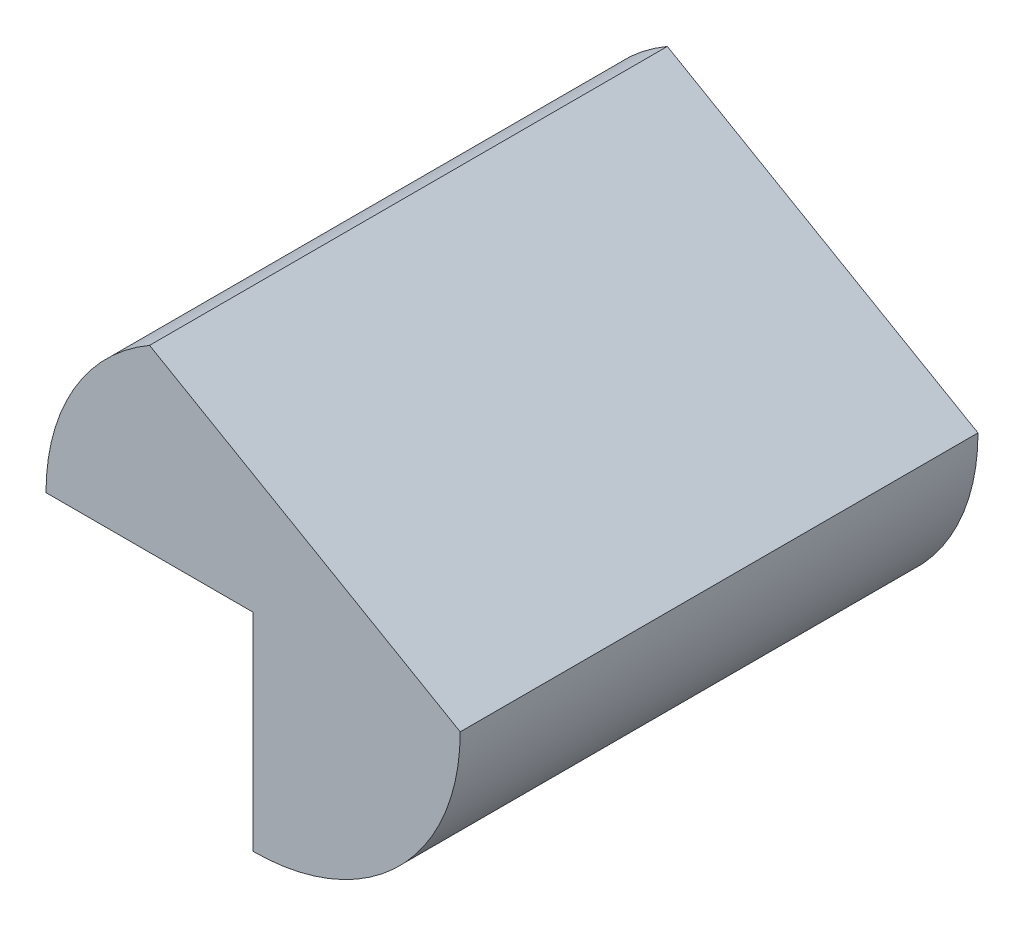
from build123d import *

# Parameters (mm, degrees)
BOSS_EXTRUDE1_DEPTH = 25


with BuildPart() as part:
    # Sketch1 → Boss-Extrude1 (new body)
    with BuildSketch(Plane.XY):
        with BuildLine():
            Line((-10, 0), (0, 0))
            Line((0, 0), (0, -10))
            ThreePointArc((0, -10), (7.071067812, -7.071067812), (10, 0))
            Line((10, 0), (-5, 8.660254038))
            ThreePointArc((-5, 8.660254038), (-8.660254038, 5), (-10, 0))
        make_face()
    extrude(amount=BOSS_EXTRUDE1_DEPTH)


solid = part.part
